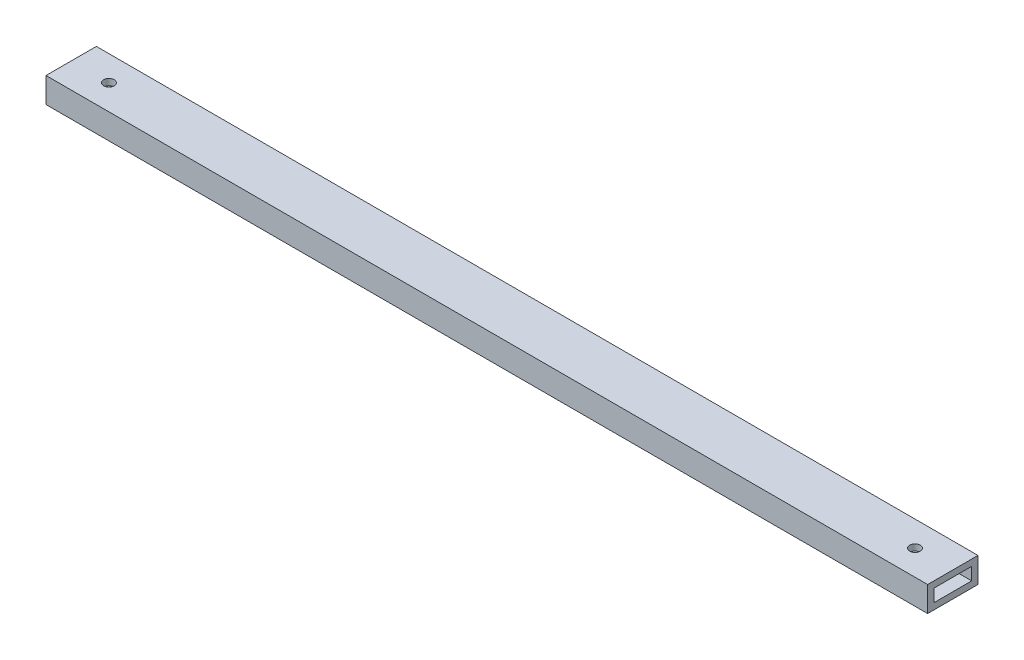
from build123d import *

# Parameters (mm, degrees)
SKETCH1_W           = 25.4
SKETCH1_H           = 12.7
SKETCH1_W_2         = 19.05
SKETCH1_H_2         = 6.35
BOSS_EXTRUDE1_DEPTH = 444.5
SKETCH2_R           = 2.667
CUT_EXTRUDE1_DEPTH  = 13.7


with BuildPart() as part:
    # Sketch1 → Boss-Extrude1 (new body)
    with BuildSketch(Plane(origin=(0, 0, 0), x_dir=(0, 0, -1), z_dir=(1, 0, 0))):
        with Locations((12.7, 6.35)):
            Rectangle(SKETCH1_W, SKETCH1_H)
        with Locations((12.7, 6.35)):
            Rectangle(SKETCH1_W_2, SKETCH1_H_2, mode=Mode.SUBTRACT)
    extrude(amount=BOSS_EXTRUDE1_DEPTH)

    # Sketch2 → Cut-Extrude1 (cut, through all)
    with BuildSketch(Plane(origin=(0, 12.7, 0), x_dir=(1, 0, 0), z_dir=(0, 1, 0))):
        with Locations((19.05, 12.7)):
            Circle(SKETCH2_R)
        with Locations((425.45, 12.7)):
            Circle(SKETCH2_R)
    extrude(amount=-CUT_EXTRUDE1_DEPTH, mode=Mode.SUBTRACT)


solid = part.part
